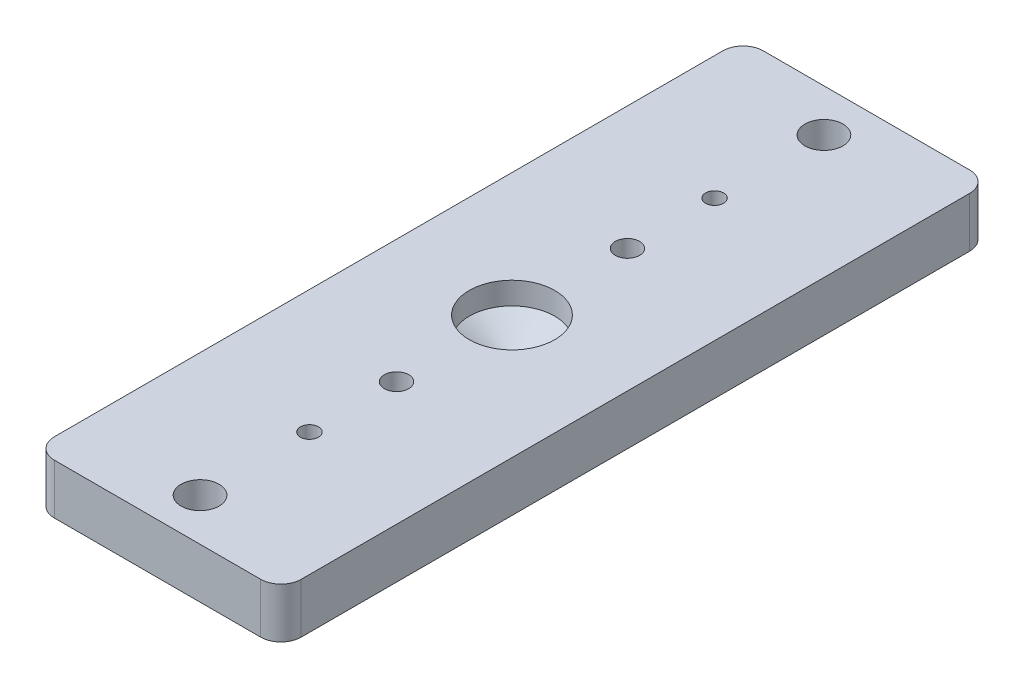
from build123d import *

# Parameters (mm, degrees)
SKETCH1_W                   = 30.95625
SKETCH1_H                   = 88.9
BOSS_EXTRUDE1_DEPTH         = 4.7625
FILLET1_R                   = 2.54
SKETCH6_R                   = 1.524
CUT_EXTRUDE1_DEPTH          = 5.7625
SKETCH7_R                   = 2.38125
CUT_EXTRUDE2_DEPTH          = 5.7625
BOSS_EXTRUDE3_DEPTH         = 1.524
F_4_40_TAPPED_HOLE1_D       = 2.2606
SKETCH10_R                  = 1.524
CUT_EXTRUDE3_DEPTH          = 2.524
SKETCH11_R                  = 3.175
CUT_EXTRUDE4_DEPTH          = 3.302
F_1_2_13_TAPPED_HOLE2_D     = 10.71626
F_1_2_13_TAPPED_HOLE2_DEPTH = 2.794
F_1_2_13_TAPPED_HOLE2_TIP   = 3.219489309


with BuildPart() as part:
    # Sketch1 → Boss-Extrude1 (new body)
    with BuildSketch(Plane(origin=(0, 0, 0), x_dir=(1, 0, 0), z_dir=(0, 1, 0))):
        Rectangle(SKETCH1_W, SKETCH1_H)
    extrude(amount=BOSS_EXTRUDE1_DEPTH)

    # Fillet1
    fillet1_edges = [part.edges().sort_by_distance(p)[0] for p in [
        (15.478125, 2.38125, -44.45),
        (15.478125, 2.38125, 44.45),
        (-15.478125, 2.38125, 44.45),
        (-15.478125, 2.38125, -44.45),
    ]]
    fillet(fillet1_edges, radius=FILLET1_R)

    # Sketch6 → Cut-Extrude1 (cut, through all)
    with BuildSketch(Plane.XZ):
        with Locations((0, 14.478)):
            Circle(SKETCH6_R)
        with Locations((0, -14.478)):
            Circle(SKETCH6_R)
    extrude(amount=-CUT_EXTRUDE1_DEPTH, mode=Mode.SUBTRACT)

    # Sketch7 → Cut-Extrude2 (cut, through all)
    with BuildSketch(Plane.XZ):
        with Locations((0, -39.116)):
            Circle(SKETCH7_R)
        with Locations((0, 39.116)):
            Circle(SKETCH7_R)
    extrude(amount=-CUT_EXTRUDE2_DEPTH, mode=Mode.SUBTRACT)

    # Sketch9 → Boss-Extrude3 (add)
    with BuildSketch(Plane.XZ):
        with BuildLine():
            Line((12.938125, -44.45), (-12.938125, -44.45))
            ThreePointArc((-12.938125, -44.45), (-14.734176224, -43.706051224), (-15.478125, -41.91))
            Line((-15.478125, -41.91), (-15.478125, 41.91))
            ThreePointArc((-15.478125, 41.91), (-14.734176224, 43.706051224), (-12.938125, 44.45))
            Line((-12.938125, 44.45), (12.938125, 44.45))
            ThreePointArc((12.938125, 44.45), (14.734176224, 43.706051224), (15.478125, 41.91))
            Line((15.478125, 41.91), (15.478125, -41.91))
            ThreePointArc((15.478125, -41.91), (14.734176224, -43.706051224), (12.938125, -44.45))
        make_face()
    extrude(amount=BOSS_EXTRUDE3_DEPTH)

    # #4-40 Tapped Hole1 (through all)
    with Locations(Plane(origin=(0, 4.7625, 0), x_dir=(-1, 0, 0), z_dir=(0, 1, 0))):
        with Locations((0, 25.4), (0, -25.4)):
            Hole(F_4_40_TAPPED_HOLE1_D / 2)

    # Sketch10 → Cut-Extrude3 (cut, through all)
    with BuildSketch(Plane(origin=(0, 0, 0), x_dir=(1, 0, 0), z_dir=(0, 1, 0))):
        with Locations((0, -14.478)):
            Circle(SKETCH10_R)
        with Locations((0, 14.478)):
            Circle(SKETCH10_R)
    extrude(amount=-CUT_EXTRUDE3_DEPTH, mode=Mode.SUBTRACT)

    # Sketch11 → Cut-Extrude4 (cut)
    with BuildSketch(Plane.XZ.offset(1.524)):
        with Locations((0, -14.478)):
            Circle(SKETCH11_R)
        with Locations((0, 14.478)):
            Circle(SKETCH11_R)
    extrude(amount=-CUT_EXTRUDE4_DEPTH, mode=Mode.SUBTRACT)

    # 1/2-13 Tapped Hole2
    with Locations(Plane(origin=(0, 4.7625, 0), x_dir=(-1, 0, 0), z_dir=(0, 1, 0))):
        with Locations((0, 0)):
            Hole(F_1_2_13_TAPPED_HOLE2_D / 2, depth=F_1_2_13_TAPPED_HOLE2_DEPTH)
            with Locations((0, 0, -(F_1_2_13_TAPPED_HOLE2_DEPTH + F_1_2_13_TAPPED_HOLE2_TIP / 2))):  # 118° drill point
                Cone(0, F_1_2_13_TAPPED_HOLE2_D / 2, F_1_2_13_TAPPED_HOLE2_TIP, mode=Mode.SUBTRACT)


solid = part.part
